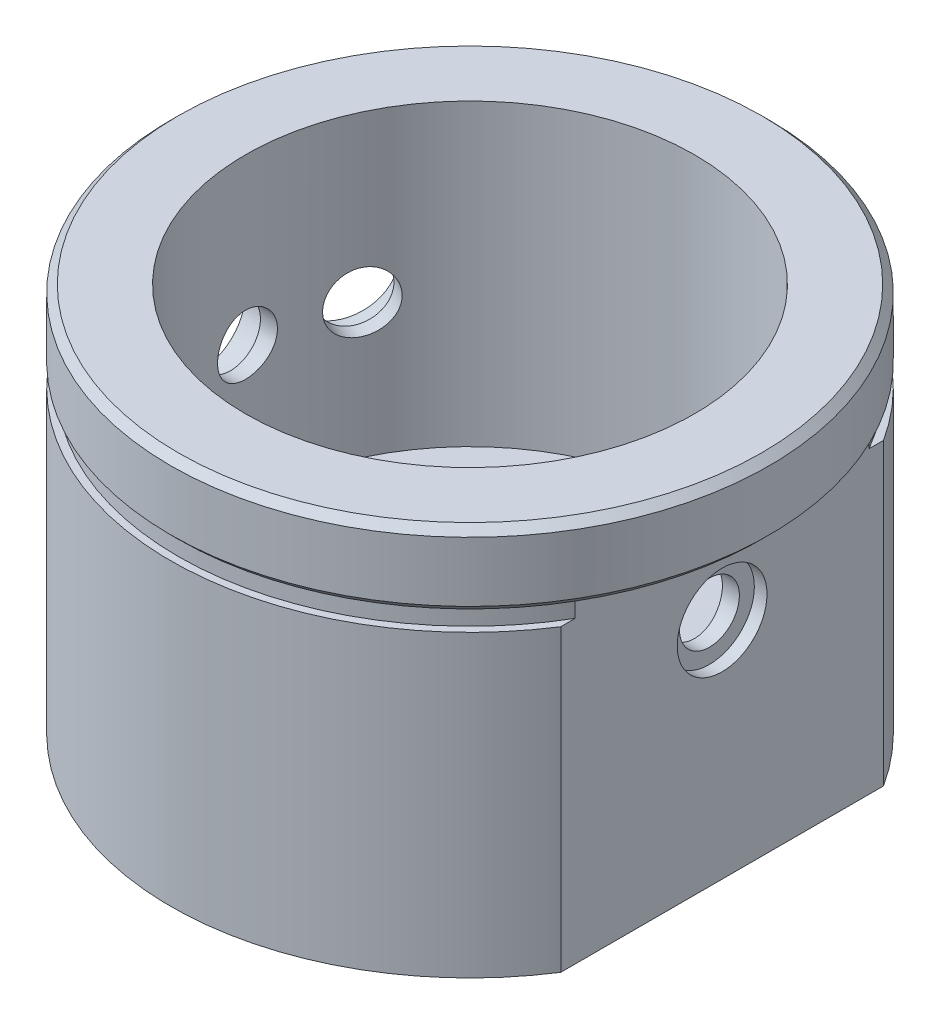
from build123d import *

# Parameters (mm, degrees)
FUROS_GUIA_COM_4_0MM2_D            = 4
FUROS_GUIA_COM_4_0MM1_REACH        = 51.881
FUROS_GUIA_COM_4_0MM1_BORE_R       = 2
ESBO_O7_W                          = 18
ESBO_O7_H                          = 6
CORTE_EXTRUS_O4_DEPTH              = 2
ESBO_O11_R                         = 3
REBAIXO_1_DEPTH                    = 2
ESBO_O13_R                         = 3
REBAIXO_2_DEPTH                    = 4
ESBO_O14_W                         = 21
ESBO_O14_H                         = 8
CORTE_EXTRUS_O8_DEPTH              = 2
ESBO_O15_W                         = 21
ESBO_O15_H                         = 8
ESBO_O15_R                         = 3
CORTE_EXTRUS_O13_DEPTH             = 2
CORTE_EXTRUS_O14_START             = -15
CORTE_EXTRUS_O14_DEPTH             = 21
ESBO_O18_R                         = 3
CORTE_EXTRUS_O15_DEPTH             = 4
CORTE_EXTRUS_O16_REACH             = 34.016
CORTE_EXTRUS_O16_DIRECTION_2_DEPTH = 6


with BuildPart() as part:
    # Esbo_o1 → Revolu_o1 (revolve)
    with BuildSketch(Plane.XY, mode=Mode.PRIVATE) as revolu_o1_sk:
        Polygon((0, -15), (20, -15), (20, 5), (19.5, 5), (19.5, 6), (20, 6.5), (20, 10.5), (19.5, 11), (15, 11), (15, -9), (3.5, -9), (3.5, -12.5), (0, -12.5), align=None)
    revolve(revolu_o1_sk.sketch.rotate(Axis((0, 0, 0), (0, 1, 0)), 90), axis=Axis((0, 0, 0), (0, 1, 0)))

    # Furos-guia com _4.0mm2 (through all)
    with Locations(Plane(origin=(-20, 0, 0), x_dir=(0, 0, -1), z_dir=(-1, 0, 0))):
        with Locations((0, 0)):
            Hole(FUROS_GUIA_COM_4_0MM2_D / 2)

    # Furos-guia com _4.0mm1 bore (on position points) → Furos-guia com _4.0mm1 (cut, up to next)
    with BuildSketch(Plane(origin=(-18.126155741, 0, -8.452365235), x_dir=(0.422618261741, 0, -0.906307787037), z_dir=(-0.906307787037, 0, -0.422618261741)), mode=Mode.PRIVATE) as furos_guia_com_4_0mm1_sk1:
        Circle(FUROS_GUIA_COM_4_0MM1_BORE_R)
    furos_guia_com_4_0mm1_tool1 = extrude(furos_guia_com_4_0mm1_sk1.sketch, amount=-FUROS_GUIA_COM_4_0MM1_REACH, mode=Mode.PRIVATE) & part.part
    add(furos_guia_com_4_0mm1_tool1.solids().sort_by_distance((-18.126156, 0, -8.452365))[0], mode=Mode.SUBTRACT)

    # Esbo_o7 → Corte-extrus_o4 (cut)
    with BuildSketch(Plane(origin=(20, 0, 0), x_dir=(0, -1, 0), z_dir=(1, 0, 0))):
        with Locations((6, 0)):
            Rectangle(ESBO_O7_W, ESBO_O7_H)
    extrude(amount=-CORTE_EXTRUS_O4_DEPTH, mode=Mode.SUBTRACT)

    # Esbo_o11 → Rebaixo 1 (cut)
    with BuildSketch(Plane(origin=(18, 0, 0), x_dir=(0, 0, -1), z_dir=(1, 0, 0))):
        Circle(ESBO_O11_R)
    extrude(amount=-REBAIXO_1_DEPTH, mode=Mode.SUBTRACT)

    # Esbo_o13 → Rebaixo 2 (cut)
    with BuildSketch(Plane(origin=(-18.126155741, 0, -8.452365235), x_dir=(0, -1, 0), z_dir=(-0.9063077870366467, 0, -0.4226182617407065))):
        with Locations(Location((0, 0, 0), (0, 0, 90))):
            Circle(ESBO_O13_R)
    extrude(amount=-REBAIXO_2_DEPTH, mode=Mode.SUBTRACT)

    # Esbo_o14 → Corte-extrus_o8 (cut)
    with BuildSketch(Plane(origin=(-18.126155741, 0, -8.452365235), x_dir=(0, -1, 0), z_dir=(-0.9063077870366467, 0, -0.4226182617407065))):
        with Locations((4.5, 0)):
            Rectangle(ESBO_O14_W, ESBO_O14_H)
    extrude(amount=-CORTE_EXTRUS_O8_DEPTH, mode=Mode.SUBTRACT)

    # Esbo_o15 → Corte-extrus_o13 (cut)
    with BuildSketch(Plane(origin=(-20, 0, 0), x_dir=(0, -1, 0), z_dir=(-1, 0, 0))):
        with Locations((4.5, 0)):
            Rectangle(ESBO_O15_W, ESBO_O15_H)
        with Locations(Location((0, 0, 0), (0, 0, 270))):
            Circle(ESBO_O15_R, mode=Mode.SUBTRACT)
    extrude(amount=-CORTE_EXTRUS_O13_DEPTH, mode=Mode.SUBTRACT)

    # Esbo_o17 → Corte-extrus_o14 (cut)
    with BuildSketch(Plane(origin=(0, 0, 0), x_dir=(1, 0, 0), z_dir=(0, 1, 0)).offset(CORTE_EXTRUS_O14_START)):
        with BuildLine():
            Line((-18, 3.990503928), (-18, -8.717797887))
            ThreePointArc((-18, -8.717797887), (-19.525920142, 4.328792279), (-12.629239577, 15.508136822))
            Line((-12.629239577, 15.508136822), (-18, 3.990503928))
        make_face()
    extrude(amount=CORTE_EXTRUS_O14_DEPTH, mode=Mode.SUBTRACT)

    # Esbo_o18 → Corte-extrus_o15 (cut)
    with BuildSketch(Plane(origin=(-20, 0, 0), x_dir=(0, -1, 0), z_dir=(-1, 0, 0))):
        with Locations(Location((0, 0, 0), (0, 0, 270))):
            Circle(ESBO_O18_R)
    extrude(amount=-CORTE_EXTRUS_O15_DEPTH, mode=Mode.SUBTRACT)

    # Esbo_o9 → Corte-extrus_o16 (cut, up to next)
    with BuildSketch(Plane(origin=(0, 0, 0), x_dir=(1, 0, 0), z_dir=(0, 1, 0)), mode=Mode.PRIVATE) as corte_extrus_o16_sk1:
        with BuildLine():
            Line((16.845642244, 10.780739186), (16.845642244, -10.780739186))
            ThreePointArc((16.845642244, -10.780739186), (20, 0), (16.845642244, 10.780739186))
        make_face()
    corte_extrus_o16_tool1 = extrude(corte_extrus_o16_sk1.sketch, amount=-CORTE_EXTRUS_O16_REACH, mode=Mode.PRIVATE) & part.part
    add(corte_extrus_o16_tool1.solids().sort_by_distance((18.116323, 0, 0))[0], mode=Mode.SUBTRACT)

    # Esbo_o9 → Corte-extrus_o16 direction 2 (cut)
    with BuildSketch(Plane(origin=(0, 0, 0), x_dir=(1, 0, 0), z_dir=(0, 1, 0))):
        with BuildLine():
            Line((16.845642244, 10.780739186), (16.845642244, -10.780739186))
            ThreePointArc((16.845642244, -10.780739186), (20, 0), (16.845642244, 10.780739186))
        make_face()
    extrude(amount=CORTE_EXTRUS_O16_DIRECTION_2_DEPTH, mode=Mode.SUBTRACT)


solid = part.part
